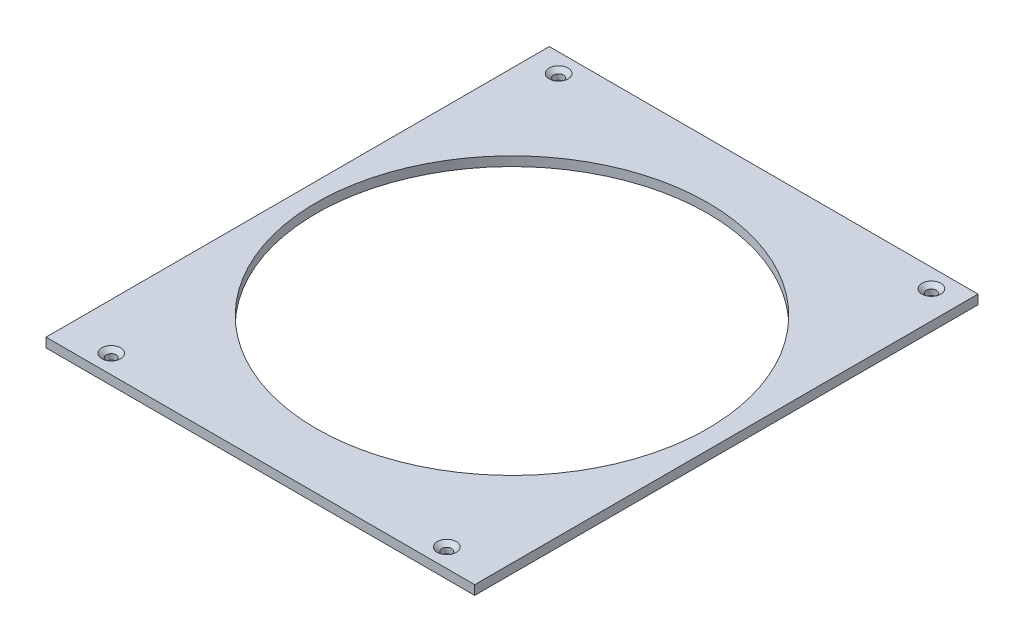
from build123d import *

# Parameters (mm, degrees)
SKETCH1_R                                           = 133.35
EXTRUDE_CENTER_HOLE_DEPTH                           = 6.35
CSK_FOR_1_4_FLAT_HEAD_MACHINE_SCREW_100_D           = 6.7564
CSK_FOR_1_4_FLAT_HEAD_MACHINE_SCREW_100_CSINK_D     = 12.8778
CSK_FOR_1_4_FLAT_HEAD_MACHINE_SCREW_100_CSINK_ANGLE = 100


with BuildPart() as part:
    # Sketch1 → Extrude & center hole (new body)
    with BuildSketch(Plane(origin=(0, 0, 0), x_dir=(1, 0, 0), z_dir=(0, 1, 0))):
        Polygon((0, 171.45), (146.05, 171.45), (146.05, 0), (146.05, -171.45), (-146.05, -171.45), (-146.05, 0), (-146.05, 171.45), align=None)
        Circle(SKETCH1_R, mode=Mode.SUBTRACT)
    extrude(amount=EXTRUDE_CENTER_HOLE_DEPTH)

    # CSK for 1/4 Flat Head Machine Screw (100)1 (through all)
    with Locations(Plane(origin=(0, 6.35, 0), x_dir=(1, 0, 0), z_dir=(0, 1, 0))):
        with Locations((-114.3, -158.75), (114.3, -158.75), (127, 158.75), (-127, 158.75)):
            CounterSinkHole(CSK_FOR_1_4_FLAT_HEAD_MACHINE_SCREW_100_D / 2, CSK_FOR_1_4_FLAT_HEAD_MACHINE_SCREW_100_CSINK_D / 2, counter_sink_angle=CSK_FOR_1_4_FLAT_HEAD_MACHINE_SCREW_100_CSINK_ANGLE)


solid = part.part
